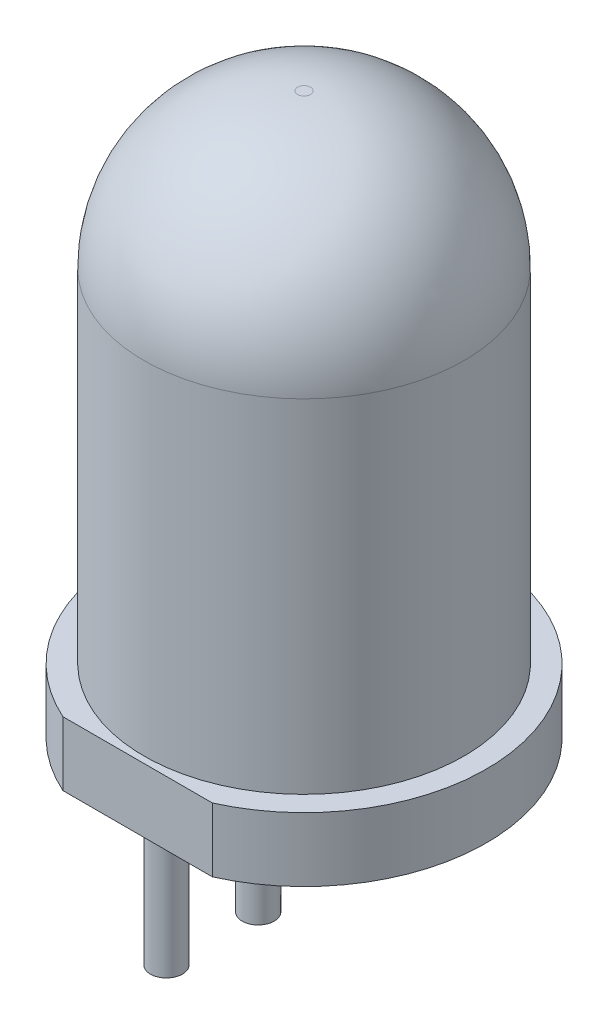
from build123d import *

# Parameters (mm, degrees)
CUT_EXTRUDE1_DEPTH  = 1
SKETCH3_R           = 0.25
BOSS_EXTRUDE1_DEPTH = 2


with BuildPart() as part:
    # Sketch1 → Revolve1 (revolve)
    with BuildSketch(Plane.XY):
        with BuildLine():
            Line((0, 0), (0, 8.75))
            Line((0, 8.75), (0.1, 8.75))
            ThreePointArc((0.1, 8.75), (1.797056275, 8.047056275), (2.5, 6.35))
            Line((2.5, 6.35), (2.5, 1))
            Line((2.5, 1), (2.85, 1))
            Line((2.85, 1), (2.85, 0))
            Line((2.85, 0), (0, 0))
        make_face()
    revolve(axis=Axis((0, 0, 0), (0, 1, 0)))

    # Sketch2 → Cut-Extrude1 (cut)
    with BuildSketch(Plane.XZ):
        with BuildLine():
            Line((-1.167261753, 2.6), (1.167261753, 2.6))
            ThreePointArc((1.167261753, 2.6), (0, 2.85), (-1.167261753, 2.6))
        make_face()
    extrude(amount=-CUT_EXTRUDE1_DEPTH, mode=Mode.SUBTRACT)

    # Sketch3 → Boss-Extrude1 (add)
    with BuildSketch(Plane.XZ):
        with Locations((0, -2.15)):
            Circle(SKETCH3_R)
        with Locations((0, 2.15)):
            Circle(SKETCH3_R)
        with Locations((0, -0.716666667)):
            Circle(SKETCH3_R)
        with Locations((0, 0.716666667)):
            Circle(SKETCH3_R)
    extrude(amount=BOSS_EXTRUDE1_DEPTH)


solid = part.part
